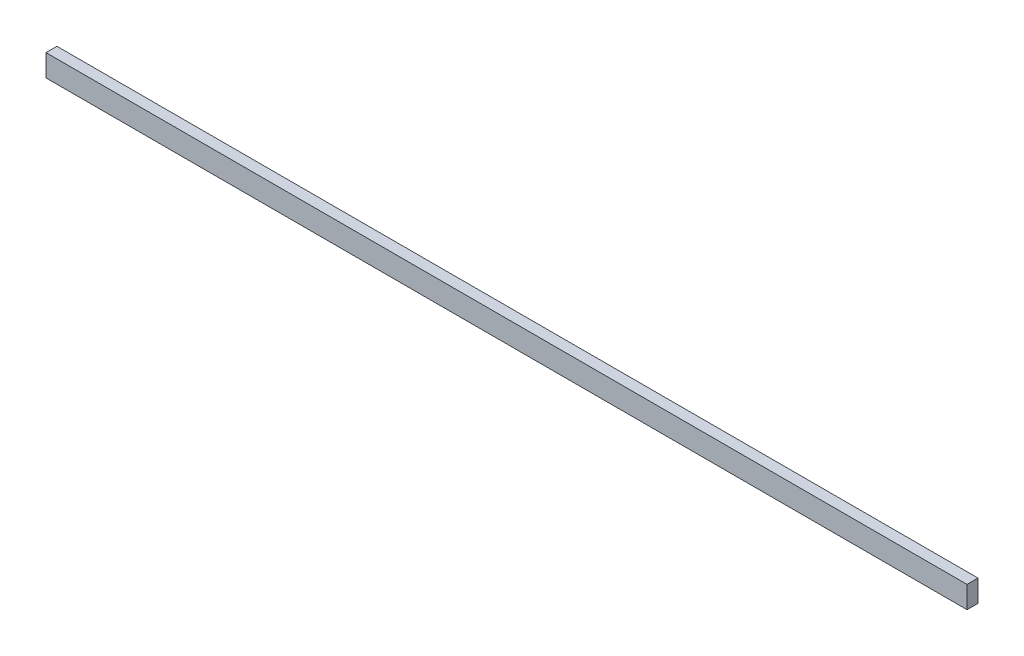
from build123d import *

# Parameters (mm, degrees)
SKETCH1_W           = 2133.6
SKETCH1_H           = 25.4
BOSS_EXTRUDE1_DEPTH = 50.8


with BuildPart() as part:
    # Sketch1 → Boss-Extrude1 (new body)
    with BuildSketch(Plane(origin=(0, 0, 0), x_dir=(1, 0, 0), z_dir=(0, 1, 0))):
        with Locations((1066.8, 12.7)):
            Rectangle(SKETCH1_W, SKETCH1_H)
    extrude(amount=BOSS_EXTRUDE1_DEPTH)


solid = part.part
